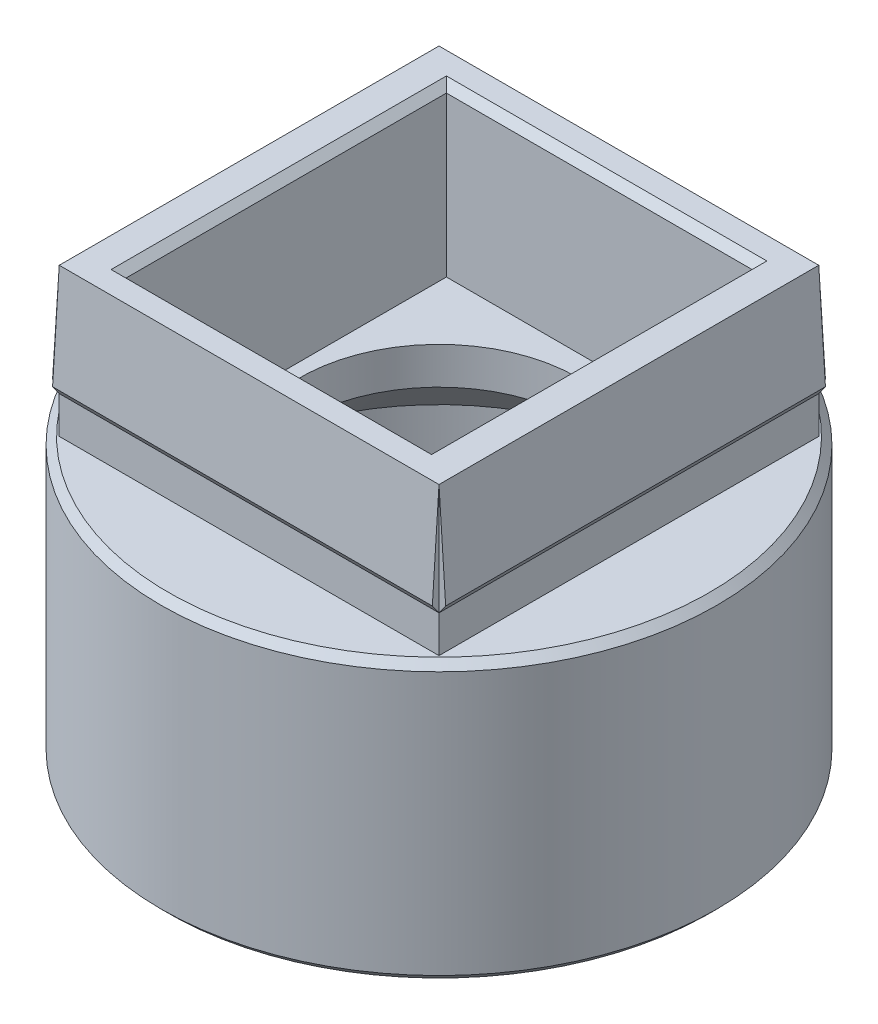
from build123d import *

# Parameters (mm, degrees)
CROQUIS1_W              = 10.25
CROQUIS1_H              = 10.25
CROQUIS1_W_2            = 8.25
CROQUIS1_H_2            = 8.65
SALIENTE_EXTRUIR1_DEPTH = 4
SALIENTE_EXTRUIR2_DEPTH = 10.25
MATRIZC1_COUNT          = 4
CROQUIS3_R              = 7.5
CROQUIS3_W              = 8.25
CROQUIS3_H              = 8.65
SALIENTE_EXTRUIR3_DEPTH = 1
CROQUIS5_R              = 7.5
CROQUIS5_R_2            = 6
SALIENTE_EXTRUIR4_DEPTH = 6.5
CHAFL_N2_SIZE           = 0.2
CHAFL_N3_SIZE           = 1
SALIENTE_EXTRUIR5_START = -4.5
CROQUIS6_R              = 6
CROQUIS6_R_2            = 3.75
SALIENTE_EXTRUIR5_DEPTH = 1
CHAFL_N4_SIZE           = 2


with BuildPart() as part:
    # Croquis1 → Saliente-Extruir1 (new body)
    with BuildSketch(Plane(origin=(0, 0, 0), x_dir=(1, 0, 0), z_dir=(0, 1, 0))):
        Rectangle(CROQUIS1_W, CROQUIS1_H)
        Rectangle(CROQUIS1_W_2, CROQUIS1_H_2, mode=Mode.SUBTRACT)
    extrude(amount=SALIENTE_EXTRUIR1_DEPTH)

    # Croquis2 → Saliente-Extruir2 (add)
    with BuildSketch(Plane(origin=(5.125, 0, 0), x_dir=(0, 0, -1), z_dir=(1, 0, 0))):
        Polygon((-5.125, 4), (-5.305, 1.25), (-5.125, 1), align=None)
    saliente_extruir2 = extrude(amount=-SALIENTE_EXTRUIR2_DEPTH)

    # MatrizC1: Saliente-Extruir2 ×4 about axis
    matrizc1_axis = Axis((0, 3.15, 0), (0, -1, 0))
    for i in range(1, MATRIZC1_COUNT):
        add(saliente_extruir2.rotate(matrizc1_axis, i * 360 / MATRIZC1_COUNT))

    # Croquis3 → Saliente-Extruir3 (add)
    with BuildSketch(Plane.XZ):
        Circle(CROQUIS3_R)
        Rectangle(CROQUIS3_W, CROQUIS3_H, mode=Mode.SUBTRACT)
    extrude(amount=SALIENTE_EXTRUIR3_DEPTH)

    # Croquis5 → Saliente-Extruir4 (add)
    with BuildSketch(Plane.XZ.offset(1)):
        Circle(CROQUIS5_R)
        Circle(CROQUIS5_R_2, mode=Mode.SUBTRACT)
    extrude(amount=SALIENTE_EXTRUIR4_DEPTH)

    # Chaflán2
    chafl_n2_edges = [part.edges().sort_by_distance(p)[0] for p in [
        (-4.125, 4, 0),
        (0, 4, 4.325),
        (4.125, 4, 0),
        (0, 4, -4.325),
        (-7.5, 0, 0),
        (-7.5, -7.5, 0),
    ]]
    chamfer(chafl_n2_edges, length=CHAFL_N2_SIZE)

    # Chaflán3
    chafl_n3_edges = [part.edges().sort_by_distance(p)[0] for p in [
        (-6, -7.5, 0),
    ]]
    chamfer(chafl_n3_edges, length=CHAFL_N3_SIZE)

    # Croquis6 → Saliente-Extruir5 (add)
    with BuildSketch(Plane(origin=(0, 4, 0), x_dir=(1, 0, 0), z_dir=(0, 1, 0)).offset(SALIENTE_EXTRUIR5_START)):
        Circle(CROQUIS6_R)
        Circle(CROQUIS6_R_2, mode=Mode.SUBTRACT)
    extrude(amount=-SALIENTE_EXTRUIR5_DEPTH)

    # Chaflán4
    chafl_n4_edges = [part.edges().sort_by_distance(p)[0] for p in [
        (-6, -1.5, 0),
    ]]
    chamfer(chafl_n4_edges, length=CHAFL_N4_SIZE)


solid = part.part
